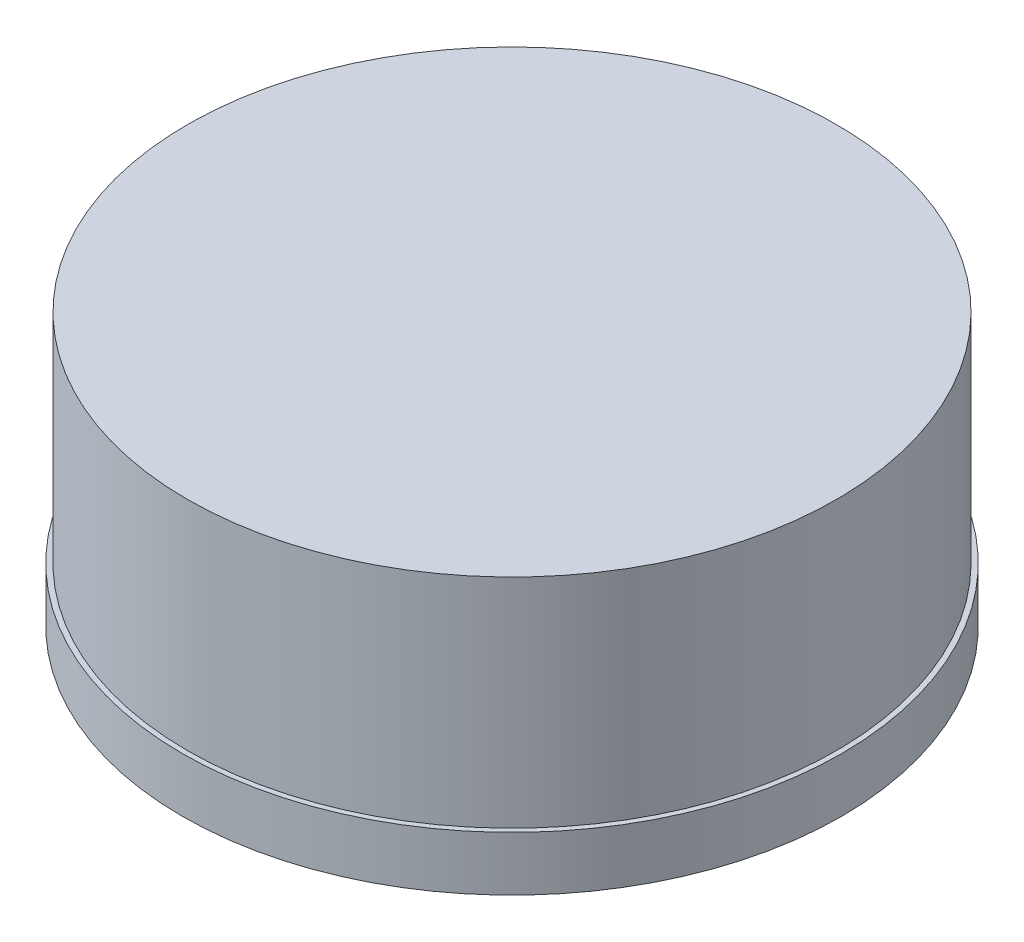
from build123d import *

# Parameters (mm, degrees)
SKETCH1_R           = 4.85
BOSS_EXTRUDE1_DEPTH = 0.8
SKETCH2_R           = 4.775
BOSS_EXTRUDE2_DEPTH = 3.2
SKETCH3_R           = 4.05
CUT_EXTRUDE1_DEPTH  = 3.2


with BuildPart() as part:
    # Sketch1 → Boss-Extrude1 (new body)
    with BuildSketch(Plane(origin=(0, 0, 0), x_dir=(1, 0, 0), z_dir=(0, 1, 0))):
        Circle(SKETCH1_R)
    extrude(amount=BOSS_EXTRUDE1_DEPTH)

    # Sketch2 → Boss-Extrude2 (add)
    with BuildSketch(Plane(origin=(0, 0.8, 0), x_dir=(1, 0, 0), z_dir=(0, 1, 0))):
        Circle(SKETCH2_R)
    extrude(amount=BOSS_EXTRUDE2_DEPTH)

    # Sketch3 → Cut-Extrude1 (cut)
    with BuildSketch(Plane(origin=(0, 0, 0), x_dir=(-1, 0, 0), z_dir=(0, -1, 0))):
        Circle(SKETCH3_R)
    extrude(amount=-CUT_EXTRUDE1_DEPTH, mode=Mode.SUBTRACT)


solid = part.part
